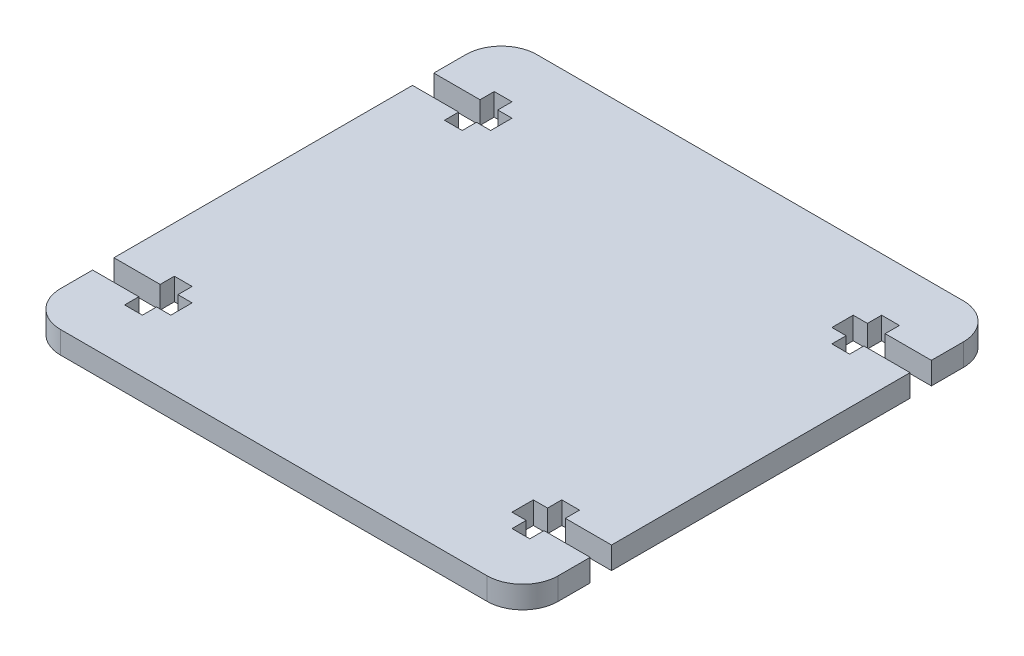
from build123d import *

# Parameters (mm, degrees)
BOSS_EXTRUDE1_DEPTH  = 1.5625
MIRROR4_COPY_1_DEPTH = 1.5625
FILLET1_R            = 5


with BuildPart() as part:
    # Sketch1 → Boss-Extrude1 (new body, symmetric)
    with BuildSketch(Plane(origin=(0, 0, 0), x_dir=(1, 0, 0), z_dir=(0, 1, 0))):
        Polygon((0, 33.5), (35, 33.5), (35, 24), (28.5, 24), (28.5, 26), (26, 26), (26, 24), (24, 24), (24, 21), (26, 21), (26, 19), (28.5, 19), (28.5, 21), (35, 21), (35, 0), (0, 0), align=None)
    boss_extrude1 = extrude(amount=BOSS_EXTRUDE1_DEPTH, both=True)

    # Mirror1: Boss-Extrude1 across plane
    add(boss_extrude1.mirror(Plane(origin=(0, 0, 0), x_dir=(0, 0, 1), z_dir=(1, 0, 0))))

    # Mirror4: Boss-Extrude1 across plane
    add(boss_extrude1.mirror(Plane.XY))

    # Mirror4 copy 1 sketch → Mirror4 copy 1 (add, symmetric)
    with BuildSketch(Plane(origin=(0, 0, 0), x_dir=(-1, 0, 0), z_dir=(0, 1, 0))):
        Polygon((0, 33.5), (35, 33.5), (35, 24), (28.5, 24), (28.5, 26), (26, 26), (26, 24), (24, 24), (24, 21), (26, 21), (26, 19), (28.5, 19), (28.5, 21), (35, 21), (35, 0), (0, 0), align=None)
    extrude(amount=MIRROR4_COPY_1_DEPTH, both=True)

    # Fillet1
    fillet1_edges = [part.edges().sort_by_distance(p)[0] for p in [
        (35, 0, 33.5),
        (35, 0, -33.5),
        (-35, 0, -33.5),
        (-35, 0, 33.5),
    ]]
    fillet(fillet1_edges, radius=FILLET1_R)


solid = part.part
